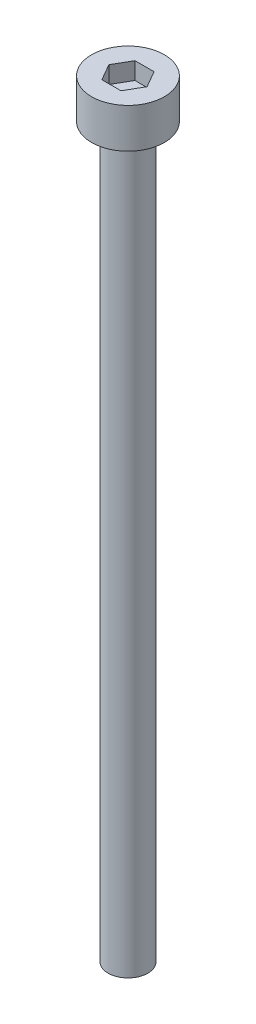
from build123d import *

# Parameters (mm, degrees)
SKETCH_1_R            = 2.75
EXTRUDE_248_DEPTH     = 3
CUT_EXTRUDE_378_DEPTH = 1.3
SKETCH_3_R            = 1.5
EXTRUDE_479_DEPTH     = 55


with BuildPart() as part:
    # 草图1 → Extrude 248 (new body)
    with BuildSketch(Plane(origin=(0, 0, 0), x_dir=(1, 0, 0), z_dir=(0, 1, 0))):
        Circle(SKETCH_1_R)
    extrude(amount=EXTRUDE_248_DEPTH)

    # 草图2 → Cut-Extrude 378 (cut)
    with BuildSketch(Plane(origin=(0, 3, 0), x_dir=(1, 0, 0), z_dir=(0, 1, 0))):
        Polygon((1.443375673, 0), (0.721687836, 1.25), (-0.721687836, 1.25), (-1.443375673, 0), (-0.721687836, -1.25), (0.721687836, -1.25), align=None)
    extrude(amount=-CUT_EXTRUDE_378_DEPTH, mode=Mode.SUBTRACT)

    # 草图3 → Extrude 479 (add)
    with BuildSketch(Plane.XZ):
        Circle(SKETCH_3_R)
    extrude(amount=EXTRUDE_479_DEPTH)


solid = part.part
